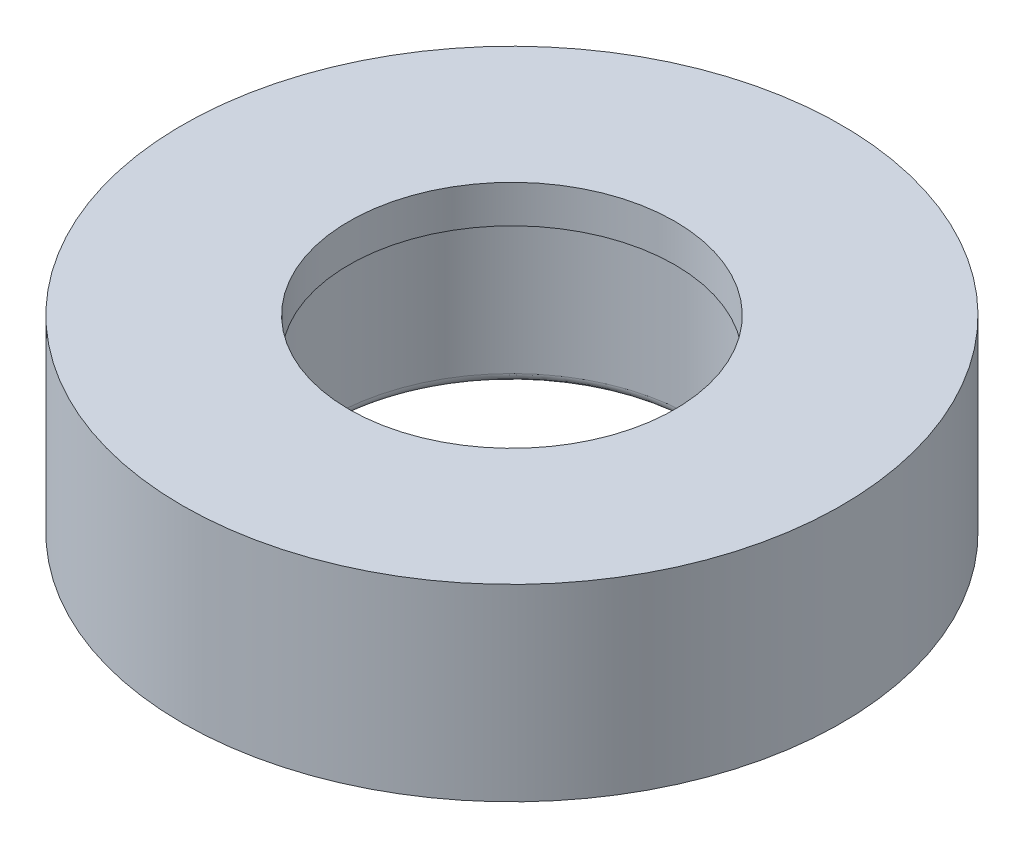
from build123d import *

# Parameters (mm, degrees)
SKETCH_1_R      = 17.5
SKETCH_1_R_2    = 9.65
EXTRUDE_1_DEPTH = 10
SKETCH_2_R      = 9.65
SKETCH_2_R_2    = 8.65
EXTRUDE_2_DEPTH = 2
FILLET_1_R      = 0.5


with BuildPart() as part:
    # Эскиз1 → Бобышка-Вытянуть1 (new body)
    with BuildSketch(Plane(origin=(0, 0, 0), x_dir=(1, 0, 0), z_dir=(0, 1, 0))):
        Circle(SKETCH_1_R)
        Circle(SKETCH_1_R_2, mode=Mode.SUBTRACT)
    extrude(amount=EXTRUDE_1_DEPTH)

    # Эскиз2 → Бобышка-Вытянуть2 (add)
    with BuildSketch(Plane(origin=(0, 10, 0), x_dir=(1, 0, 0), z_dir=(0, 1, 0))):
        Circle(SKETCH_2_R)
        Circle(SKETCH_2_R_2, mode=Mode.SUBTRACT)
    extrude(amount=-EXTRUDE_2_DEPTH)

    # Скругление1
    fillet_1_edges = [part.edges().sort_by_distance(p)[0] for p in [
        (-9.65, 0, 0),
    ]]
    fillet(fillet_1_edges, radius=FILLET_1_R)


solid = part.part
